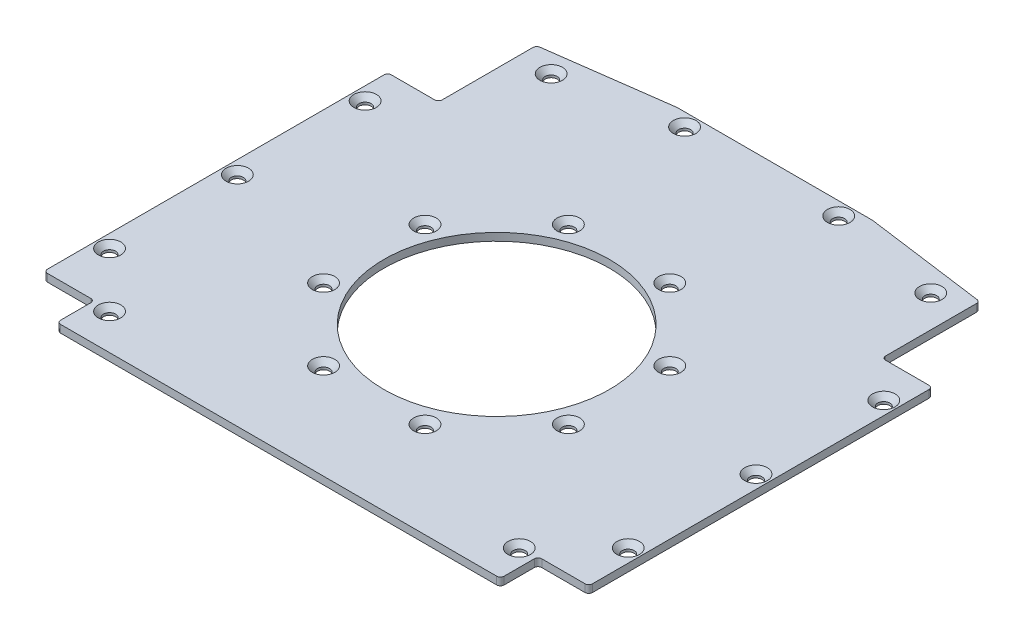
from build123d import *

# Parameters (mm, degrees)
SKETCH1_W                     = 145
SKETCH1_H                     = 132
SKETCH1_R                     = 30
BOSS_EXTRUDE1_DEPTH           = 2.032
CSK_FOR_M3_SFHCS1_AT_2_COUNT  = 2
CSK_FOR_M3_SFHCS1_AT_2_PITCH  = 26.979181982
CSK_FOR_M3_SFHCS1_AT_3_COUNT  = 2
CSK_FOR_M3_SFHCS1_AT_3_PITCH  = 49.851028074
CSK_FOR_M3_SFHCS1_AT_4_COUNT  = 2
CSK_FOR_M3_SFHCS1_AT_4_PITCH  = 65.133507042
CSK_FOR_M3_SFHCS1_AT_5_COUNT  = 2
CSK_FOR_M3_SFHCS1_AT_5_PITCH  = 70.5
CSK_FOR_M3_SFHCS1_AT_6_COUNT  = 2
CSK_FOR_M3_SFHCS1_AT_6_PITCH  = 65.133507042
CSK_FOR_M3_SFHCS1_AT_7_COUNT  = 2
CSK_FOR_M3_SFHCS1_AT_7_PITCH  = 49.851028074
CSK_FOR_M3_SFHCS1_AT_8_COUNT  = 2
CSK_FOR_M3_SFHCS1_AT_8_PITCH  = 26.979181982
CSK_FOR_M3_SFHCS2_AT_2_COUNT  = 2
CSK_FOR_M3_SFHCS2_AT_2_PITCH  = 20.506096654
CSK_FOR_M3_SFHCS2_AT_3_COUNT  = 2
CSK_FOR_M3_SFHCS2_AT_3_PITCH  = 34
CSK_FOR_M3_SFHCS2_AT_4_COUNT  = 2
CSK_FOR_M3_SFHCS2_AT_4_PITCH  = 142.126704036
CSK_FOR_M3_SFHCS2_AT_5_COUNT  = 2
CSK_FOR_M3_SFHCS2_AT_5_PITCH  = 124.348301154
CSK_FOR_M3_SFHCS2_AT_6_COUNT  = 2
CSK_FOR_M3_SFHCS2_AT_6_PITCH  = 138
CSK_FOR_M3_SFHCS2_AT_7_COUNT  = 2
CSK_FOR_M3_SFHCS2_AT_7_PITCH  = 153.844076909
CSK_FOR_M3_SFHCS2_AT_8_COUNT  = 2
CSK_FOR_M3_SFHCS2_AT_8_PITCH  = 68
CSK_FOR_M3_SFHCS2_AT_9_COUNT  = 2
CSK_FOR_M3_SFHCS2_AT_9_PITCH  = 100.713703139
CSK_FOR_M3_SFHCS2_AT_10_COUNT = 2
CSK_FOR_M3_SFHCS2_AT_10_PITCH = 115.206336631
CSK_FOR_M3_SFHCS2_AT_11_COUNT = 2
CSK_FOR_M3_SFHCS2_AT_11_PITCH = 137.58815356
CSK_FOR_M3_SFHCS2_AT_12_COUNT = 2
CSK_FOR_M3_SFHCS2_AT_12_PITCH = 155.181345528
SKETCH9_W                     = 13.5
SKETCH9_H                     = 10
CUT_EXTRUDE3_DEPTH            = 3.032
FILLET1_R                     = 1


with BuildPart() as part:
    # Sketch1 → Boss-Extrude1 (new body)
    with BuildSketch(Plane(origin=(0, 0, 0), x_dir=(1, 0, 0), z_dir=(0, 1, 0))):
        with Locations((0, 8)):
            Rectangle(SKETCH1_W, SKETCH1_H)
        Circle(SKETCH1_R, mode=Mode.SUBTRACT)
    extrude(amount=BOSS_EXTRUDE1_DEPTH)

    # Sketch2 → CSK for M3 SFHCS1 (revolve, cut)
    with BuildSketch(Plane(origin=(13.489590991, 2.032, 32.566753521), x_dir=(0, 0, 1), z_dir=(1, 0, 0))):
        Polygon((0, 0), (0, 2.032), (1.6, 2.032), (1.6, 1.4), (3, 0), align=None)
    csk_for_m3_sfhcs1 = revolve(axis=Axis((13.489590991, 8.382, 32.566753521), (0, -1, 0)), mode=Mode.SUBTRACT)

    # CSK for M3 SFHCS1 at 2: CSK for M3 SFHCS1 ×2
    with Locations(*[Vector(0.707106781, 0, -0.707106781) * (i * CSK_FOR_M3_SFHCS1_AT_2_PITCH) for i in range(1, CSK_FOR_M3_SFHCS1_AT_2_COUNT)]):
        add(csk_for_m3_sfhcs1, mode=Mode.SUBTRACT)

    # CSK for M3 SFHCS1 at 3: CSK for M3 SFHCS1 ×2
    with Locations(*[Vector(0.382683432, 0, -0.923879533) * (i * CSK_FOR_M3_SFHCS1_AT_3_PITCH) for i in range(1, CSK_FOR_M3_SFHCS1_AT_3_COUNT)]):
        add(csk_for_m3_sfhcs1, mode=Mode.SUBTRACT)

    # CSK for M3 SFHCS1 at 4: CSK for M3 SFHCS1 ×2
    with Locations(*[(0, 0, -i * CSK_FOR_M3_SFHCS1_AT_4_PITCH) for i in range(1, CSK_FOR_M3_SFHCS1_AT_4_COUNT)]):
        add(csk_for_m3_sfhcs1, mode=Mode.SUBTRACT)

    # CSK for M3 SFHCS1 at 5: CSK for M3 SFHCS1 ×2
    with Locations(*[Vector(-0.382683432, 0, -0.923879533) * (i * CSK_FOR_M3_SFHCS1_AT_5_PITCH) for i in range(1, CSK_FOR_M3_SFHCS1_AT_5_COUNT)]):
        add(csk_for_m3_sfhcs1, mode=Mode.SUBTRACT)

    # CSK for M3 SFHCS1 at 6: CSK for M3 SFHCS1 ×2
    with Locations(*[Vector(-0.707106781, 0, -0.707106781) * (i * CSK_FOR_M3_SFHCS1_AT_6_PITCH) for i in range(1, CSK_FOR_M3_SFHCS1_AT_6_COUNT)]):
        add(csk_for_m3_sfhcs1, mode=Mode.SUBTRACT)

    # CSK for M3 SFHCS1 at 7: CSK for M3 SFHCS1 ×2
    with Locations(*[Vector(-0.923879533, 0, -0.382683432) * (i * CSK_FOR_M3_SFHCS1_AT_7_PITCH) for i in range(1, CSK_FOR_M3_SFHCS1_AT_7_COUNT)]):
        add(csk_for_m3_sfhcs1, mode=Mode.SUBTRACT)

    # CSK for M3 SFHCS1 at 8: CSK for M3 SFHCS1 ×2
    with Locations(*[(-i * CSK_FOR_M3_SFHCS1_AT_8_PITCH, 0, 0) for i in range(1, CSK_FOR_M3_SFHCS1_AT_8_COUNT)]):
        add(csk_for_m3_sfhcs1, mode=Mode.SUBTRACT)

    # Sketch5 → CSK for M3 SFHCS2 (revolve, cut)
    with BuildSketch(Plane(origin=(-69, 2.032, 34), x_dir=(0, 0, 1), z_dir=(1, 0, 0))):
        Polygon((0, 0), (0, 2.032), (1.6, 2.032), (1.6, 1.4), (3, 0), align=None)
    csk_for_m3_sfhcs2 = revolve(axis=Axis((-69, 8.382, 34), (0, -1, 0)), mode=Mode.SUBTRACT)

    # CSK for M3 SFHCS2 at 2: CSK for M3 SFHCS2 ×2
    with Locations(*[Vector(0.707106781, 0, 0.707106781) * (i * CSK_FOR_M3_SFHCS2_AT_2_PITCH) for i in range(1, CSK_FOR_M3_SFHCS2_AT_2_COUNT)]):
        add(csk_for_m3_sfhcs2, mode=Mode.SUBTRACT)

    # CSK for M3 SFHCS2 at 3: CSK for M3 SFHCS2 ×2
    with Locations(*[(0, 0, -i * CSK_FOR_M3_SFHCS2_AT_3_PITCH) for i in range(1, CSK_FOR_M3_SFHCS2_AT_3_COUNT)]):
        add(csk_for_m3_sfhcs2, mode=Mode.SUBTRACT)

    # CSK for M3 SFHCS2 at 4: CSK for M3 SFHCS2 ×2
    with Locations(*[Vector(0.970964612, 0, -0.239223165) * (i * CSK_FOR_M3_SFHCS2_AT_4_PITCH) for i in range(1, CSK_FOR_M3_SFHCS2_AT_4_COUNT)]):
        add(csk_for_m3_sfhcs2, mode=Mode.SUBTRACT)

    # CSK for M3 SFHCS2 at 5: CSK for M3 SFHCS2 ×2
    with Locations(*[Vector(0.993178024, 0, 0.116607946) * (i * CSK_FOR_M3_SFHCS2_AT_5_PITCH) for i in range(1, CSK_FOR_M3_SFHCS2_AT_5_COUNT)]):
        add(csk_for_m3_sfhcs2, mode=Mode.SUBTRACT)

    # CSK for M3 SFHCS2 at 6: CSK for M3 SFHCS2 ×2
    with Locations(*[(i * CSK_FOR_M3_SFHCS2_AT_6_PITCH, 0, 0) for i in range(1, CSK_FOR_M3_SFHCS2_AT_6_COUNT)]):
        add(csk_for_m3_sfhcs2, mode=Mode.SUBTRACT)

    # CSK for M3 SFHCS2 at 7: CSK for M3 SFHCS2 ×2
    with Locations(*[Vector(0.89701211, 0, -0.442005967) * (i * CSK_FOR_M3_SFHCS2_AT_7_PITCH) for i in range(1, CSK_FOR_M3_SFHCS2_AT_7_COUNT)]):
        add(csk_for_m3_sfhcs2, mode=Mode.SUBTRACT)

    # CSK for M3 SFHCS2 at 8: CSK for M3 SFHCS2 ×2
    with Locations(*[(0, 0, -i * CSK_FOR_M3_SFHCS2_AT_8_PITCH) for i in range(1, CSK_FOR_M3_SFHCS2_AT_8_COUNT)]):
        add(csk_for_m3_sfhcs2, mode=Mode.SUBTRACT)

    # CSK for M3 SFHCS2 at 9: CSK for M3 SFHCS2 ×2
    with Locations(*[Vector(0.183689006, 0, -0.982984409) * (i * CSK_FOR_M3_SFHCS2_AT_9_PITCH) for i in range(1, CSK_FOR_M3_SFHCS2_AT_9_COUNT)]):
        add(csk_for_m3_sfhcs2, mode=Mode.SUBTRACT)

    # CSK for M3 SFHCS2 at 10: CSK for M3 SFHCS2 ×2
    with Locations(*[Vector(0.420983788, 0, -0.907068162) * (i * CSK_FOR_M3_SFHCS2_AT_10_PITCH) for i in range(1, CSK_FOR_M3_SFHCS2_AT_10_COUNT)]):
        add(csk_for_m3_sfhcs2, mode=Mode.SUBTRACT)

    # CSK for M3 SFHCS2 at 11: CSK for M3 SFHCS2 ×2
    with Locations(*[Vector(0.65049205, 0, -0.759513063) * (i * CSK_FOR_M3_SFHCS2_AT_11_PITCH) for i in range(1, CSK_FOR_M3_SFHCS2_AT_11_COUNT)]):
        add(csk_for_m3_sfhcs2, mode=Mode.SUBTRACT)

    # CSK for M3 SFHCS2 at 12: CSK for M3 SFHCS2 ×2
    with Locations(*[Vector(0.770066786, 0, -0.637963279) * (i * CSK_FOR_M3_SFHCS2_AT_12_PITCH) for i in range(1, CSK_FOR_M3_SFHCS2_AT_12_COUNT)]):
        add(csk_for_m3_sfhcs2, mode=Mode.SUBTRACT)

    # Sketch9 → Cut-Extrude3 (cut, through all)
    with BuildSketch(Plane(origin=(0, 2.032, 0), x_dir=(1, 0, 0), z_dir=(0, 1, 0))):
        with Locations((-65.75, -53)):
            Rectangle(SKETCH9_W, SKETCH9_H)
        with Locations((65.75, -53)):
            Rectangle(SKETCH9_W, SKETCH9_H)
        Polygon((-26, 74), (-59, 69.528648916), (-59, 43.5), (-72.5, 43.5), (-72.5, 74), align=None)
        Polygon((72.5, 74), (72.5, 43.5), (59, 43.5), (59, 69.528648916), (26, 74), align=None)
    extrude(amount=-CUT_EXTRUDE3_DEPTH, mode=Mode.SUBTRACT)

    # Fillet1
    fillet1_edges = [part.edges().sort_by_distance(p)[0] for p in [
        (-72.5, 1.016, 48),
        (-59, 1.016, 48),
        (-59, 1.016, 58),
        (72.5, 1.016, 48),
        (59, 1.016, 58),
        (59, 1.016, 48),
        (-59, 1.016, -69.528648916),
        (-59, 1.016, -43.5),
        (-72.5, 1.016, -43.5),
        (72.5, 1.016, -43.5),
        (59, 1.016, -43.5),
        (59, 1.016, -69.528648916),
    ]]
    fillet(fillet1_edges, radius=FILLET1_R)


solid = part.part
